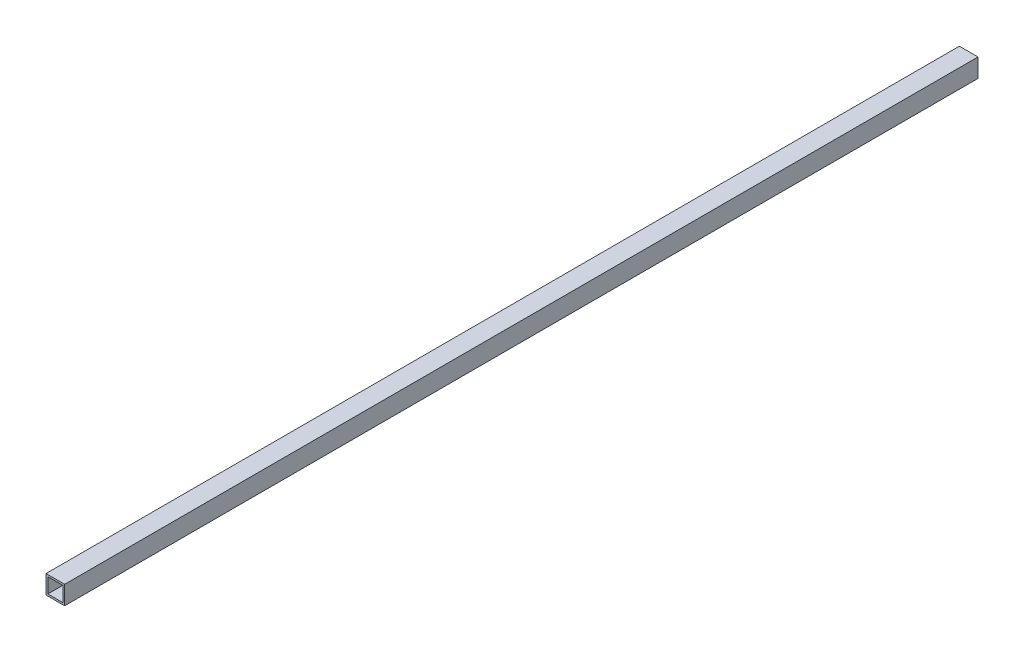
from build123d import *

# Parameters (mm, degrees)
SKETCH1_W   = 40
SKETCH1_H   = 40
SKETCH1_W_2 = 32
SKETCH1_H_2 = 32


with BuildPart() as part:
    # Sweep1: sweep along a curve in space
    with BuildLine() as sweep1_path:
        add(Edge.make_bspline(
            [(0, 0, 0), (0, 0, 1960)],
            knots=[0, 0, 1, 1], degree=1))
    # Sketch1 → Sweep1 (sweep)
    with BuildSketch(Plane.XY):
        Rectangle(SKETCH1_W, SKETCH1_H)
        Rectangle(SKETCH1_W_2, SKETCH1_H_2, mode=Mode.SUBTRACT)
    sweep(path=sweep1_path.line)


solid = part.part
